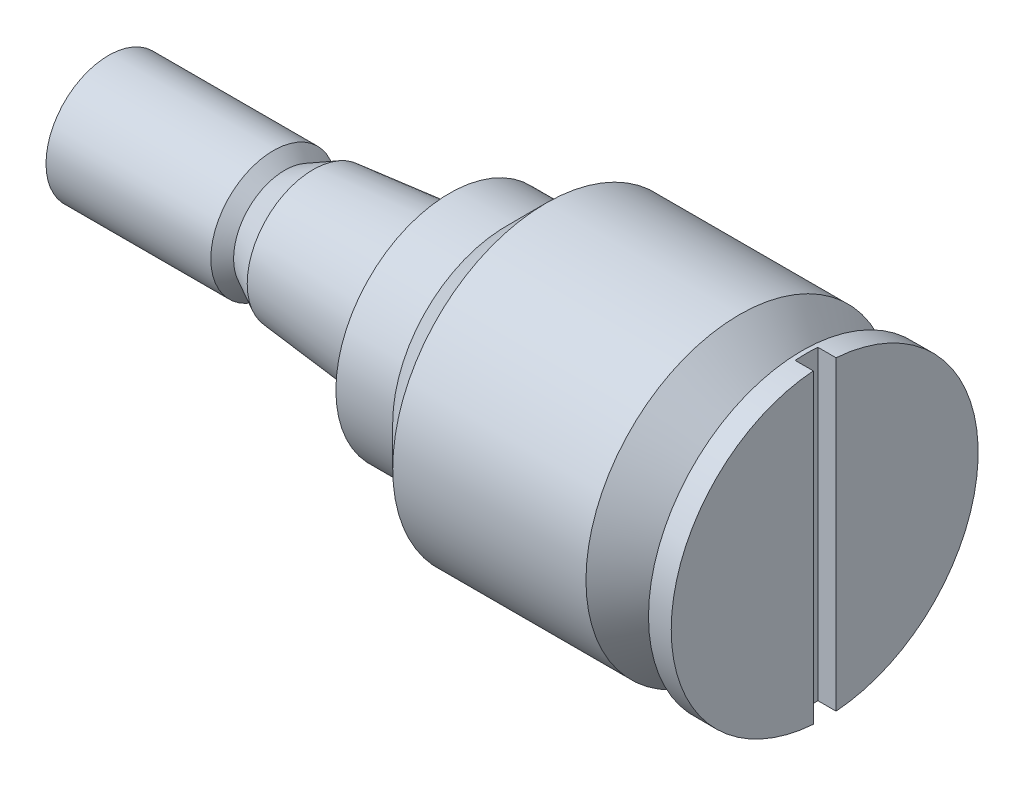
from build123d import *

# Parameters (mm, degrees)
SKETCH_2_W               = 1.6
SKETCH_2_H               = 2
CUT_EXTRUDE_1_DEPTH      = 14.5
CUT_EXTRUDE_1_DEPTH_BACK = 14.5


with BuildPart() as part:
    # Эскиз1 → Повернуть1 (revolve)
    with BuildSketch(Plane.XY):
        Polygon((-31.5, 0), (31.5, 0), (31.5, 13.5), (29.5, 13.5), (29.5, 10), (27.5, 10), (24, 13.5), (7, 13.5), (3.5, 10), (-1.5, 10), (-1.5, 7), (-13.5, 5.8), (-16, 4.5), (-17, 5.5), (-31.5, 5.5), align=None)
    revolve(axis=Axis((-261.918227013, 0, 0), (1, 0, 0)))

    # Эскиз2 → Вырез-Вытянуть1 (cut, two sides)
    with BuildSketch(Plane(origin=(0, 0, 0), x_dir=(1, 0, 0), z_dir=(0, 1, 0))) as cut_extrude_1_sk:
        with Locations((30.7, 0)):
            Rectangle(SKETCH_2_W, SKETCH_2_H)
    extrude(amount=CUT_EXTRUDE_1_DEPTH, mode=Mode.SUBTRACT)
    extrude(cut_extrude_1_sk.sketch, amount=-CUT_EXTRUDE_1_DEPTH_BACK, mode=Mode.SUBTRACT)


solid = part.part
